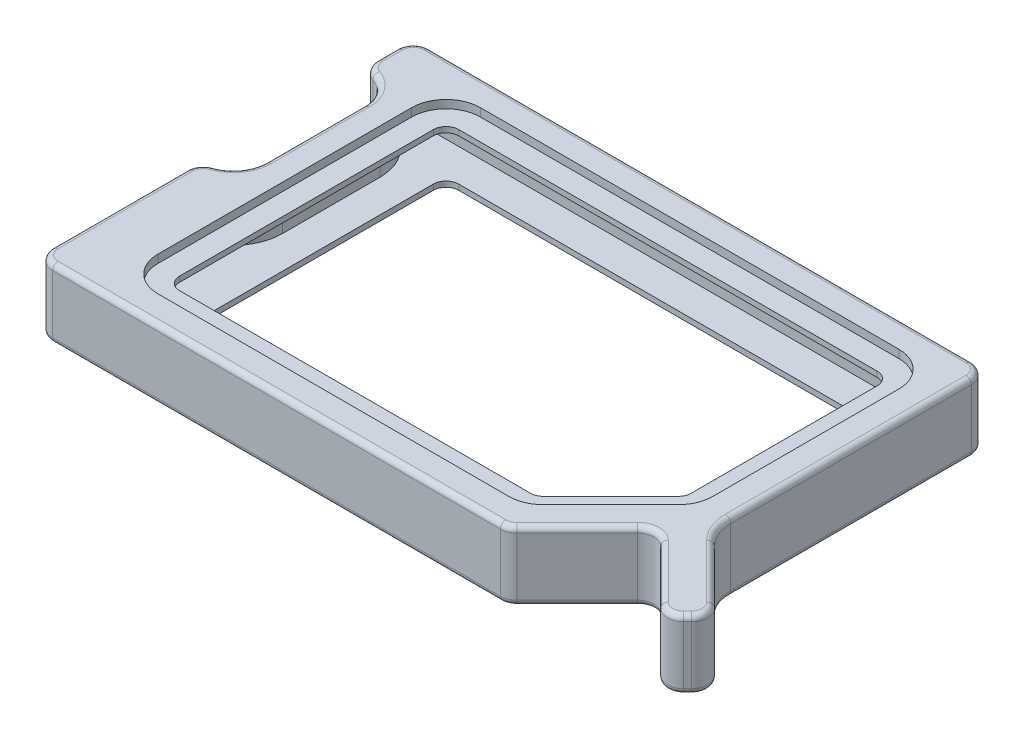
from build123d import *

# Parameters (mm, degrees)
SKETCH1_W           = 120
SKETCH1_H           = 69.434382776
BOSS_EXTRUDE1_DEPTH = 6.35
CUT_EXTRUDE1_DEPTH  = 7.35
FILLET1_R           = 3
BOSS_EXTRUDE2_DEPTH = 6.35
CUT_EXTRUDE2_DEPTH  = 1.5
FILLET2_R           = 6.35
CUT_EXTRUDE3_REACH  = 6.85
CUT_EXTRUDE4_DEPTH  = 3.85
BOSS_EXTRUDE3_DEPTH = 3.85
FILLET4_R           = 1
SKETCH8_R           = 1.799581827
CUT_EXTRUDE5_DEPTH  = 21
FILLET5_R           = 1
CUT_EXTRUDE6_START  = -3.5
SKETCH9_W           = 12.800190858
SKETCH9_H           = 9.638233658
CUT_EXTRUDE6_DEPTH  = 1.6


with BuildPart() as part:
    # Sketch1 → Boss-Extrude1 (new body)
    with BuildSketch(Plane(origin=(0, 0, 0), x_dir=(1, 0, 0), z_dir=(0, 1, 0))):
        Rectangle(SKETCH1_W, SKETCH1_H)
    extrude(amount=BOSS_EXTRUDE1_DEPTH)

    # Sketch2 → Cut-Extrude1 (cut, through all)
    with BuildSketch(Plane(origin=(0, 6.35, 0), x_dir=(1, 0, 0), z_dir=(0, 1, 0))):
        with BuildLine():
            Line((-53.945604382, 19.556024572), (-53.945604382, 1.562036653))
            ThreePointArc((-53.945604382, 1.562036653), (-60, -4.492358965), (-66.054395618, 1.562036653))
            Line((-66.054395618, 1.562036653), (-66.054395618, 19.556024572))
            ThreePointArc((-66.054395618, 19.556024572), (-60, 25.61042019), (-53.945604382, 19.556024572))
        make_face()
        Polygon((26.765981284, -34.717191388), (40.908116908, -20.575055764), (55.050252532, -34.717191388), (60, -29.767443919), (45.857864376, -15.625308296), (45.857864376, 34.717191388), (85.563511745, 34.717191388), (85.563511745, -46.950332747), (26.765981284, -46.950332747), align=None)
    extrude(amount=-CUT_EXTRUDE1_DEPTH, mode=Mode.SUBTRACT)

    # Fillet1
    fillet1_edges = [part.edges().sort_by_distance(p)[0] for p in [
        (-60, 3.175, -25.61042019),
        (-60, 3.175, 4.492358965),
        (45.857864376, 3.175, -34.717191388),
        (26.765981284, 3.175, 34.717191388),
        (40.908116908, 3.175, 20.575055764),
        (55.050252532, 3.175, 34.717191388),
        (60, 3.175, 29.767443919),
        (-60, 3.175, -34.717191388),
        (-60, 3.175, 34.717191388),
    ]]
    fillet(fillet1_edges, radius=FILLET1_R)

    # Sketch3 → Boss-Extrude2 (add)
    with BuildSketch(Plane(origin=(0, 6.35, 0), x_dir=(1, 0, 0), z_dir=(0, 1, 0))):
        with BuildLine():
            Line((47.97918472, -17.746628639), (49.552046941, -19.31949086))
            Line((49.552046941, -19.31949086), (42.644119977, -16.529838006))
            Line((42.644119977, -16.529838006), (45.857864376, -12.623439694))
            ThreePointArc((45.857864376, -12.623439694), (46.408820018, -15.39608369), (47.97918472, -17.746628639))
        make_face()
    extrude(amount=-BOSS_EXTRUDE2_DEPTH)

    # Sketch4 → Cut-Extrude2 (cut)
    with BuildSketch(Plane(origin=(0, 6.35, 0), x_dir=(1, 0, 0), z_dir=(0, 1, 0))):
        Polygon((-48.945604382, 29.717191388), (-48.945604382, -29.717191388), (24.694913472, -29.717191388), (40.857864376, -13.554240484), (40.857864376, 29.717191388), align=None)
    extrude(amount=-CUT_EXTRUDE2_DEPTH, mode=Mode.SUBTRACT)

    # Fillet2
    fillet2_edges = [part.edges().sort_by_distance(p)[0] for p in [
        (-48.945604382, 5.6, -29.717191388),
        (40.857864376, 5.6, -29.717191388),
        (40.857864376, 5.6, 13.554240484),
        (24.694913472, 5.6, 29.717191388),
        (-48.945604382, 5.6, 29.717191388),
    ]]
    fillet(fillet2_edges, radius=FILLET2_R)

    # Sketch5 → Cut-Extrude3 (cut, up to next)
    with BuildSketch(Plane(origin=(0, 4.85, 0), x_dir=(1, 0, 0), z_dir=(0, 1, 0)), mode=Mode.PRIVATE) as cut_extrude3_sk1:
        with BuildLine():
            Line((-44.945604382, 23.367191388), (-44.945604382, -23.367191388))
            ThreePointArc((-44.945604382, -23.367191388), (-44.257305317, -25.028892323), (-42.595604382, -25.717191388))
            Line((-42.595604382, -25.717191388), (22.064657351, -25.717191388))
            ThreePointArc((22.064657351, -25.717191388), (22.963963417, -25.538308289), (23.726358287, -25.028892323))
            Line((23.726358287, -25.028892323), (36.169565312, -12.585685298))
            ThreePointArc((36.169565312, -12.585685298), (36.678981278, -11.823290429), (36.857864376, -10.923984363))
            Line((36.857864376, -10.923984363), (36.857864376, 23.367191388))
            ThreePointArc((36.857864376, 23.367191388), (36.169565312, 25.028892323), (34.507864376, 25.717191388))
            Line((34.507864376, 25.717191388), (-42.595604382, 25.717191388))
            ThreePointArc((-42.595604382, 25.717191388), (-44.257305317, 25.028892323), (-44.945604382, 23.367191388))
        make_face()
    cut_extrude3_tool1 = extrude(cut_extrude3_sk1.sketch, amount=-CUT_EXTRUDE3_REACH, mode=Mode.PRIVATE) & part.part
    add(cut_extrude3_tool1.solids().sort_by_distance((-4.877844, 4.85, -0.484519))[0], mode=Mode.SUBTRACT)

    # Sketch6 → Cut-Extrude4 (cut)
    with BuildSketch(Plane.XZ):
        with BuildLine():
            Line((42.857864376, -31.717191388), (42.857864376, 12.625307714))
            ThreePointArc((42.857864376, 12.625307714), (43.637538907, 16.544996877), (45.857864461, 19.867948897))
            Line((45.857864461, 19.867948897), (55.757359313, 29.767443919))
            Line((55.757359313, 29.767443919), (55.050252532, 30.4745507))
            Line((55.050252532, 30.4745507), (45.150757595, 20.575055764))
            ThreePointArc((45.150757595, 20.575055764), (40.908116908, 18.817696451), (36.665476221, 20.575055764))
            Line((36.665476221, 20.575055764), (25.523340597, 31.717191388))
            Line((25.523340597, 31.717191388), (-57, 31.717191388))
            Line((-57, 31.717191388), (-57, 6.98091834))
            ThreePointArc((-57, 6.98091834), (-52.612670751, 3.673366538), (-50.945604382, -1.562036653))
            Line((-50.945604382, -1.562036653), (-50.945604382, -19.556024572))
            ThreePointArc((-50.945604382, -19.556024572), (-52.612670751, -24.791427763), (-57, -28.098979565))
            Line((-57, -28.098979565), (-57, -31.717191388))
            Line((-57, -31.717191388), (42.857864376, -31.717191388))
        make_face()
    extrude(amount=-CUT_EXTRUDE4_DEPTH, mode=Mode.SUBTRACT)

    # Sketch7 → Boss-Extrude3 (add)
    with BuildSketch(Plane.XZ):
        with BuildLine():
            ThreePointArc((42.857864376, 12.625307714), (42.534912477, 14.248896552), (41.615223278, 15.625308707))
            Line((41.615223278, 15.625308707), (36.665476221, 20.575055764))
            ThreePointArc((36.665476221, 20.575055764), (40.908116908, 18.817696451), (45.150757595, 20.575055764))
            Line((45.150757595, 20.575055764), (55.050252532, 30.4745507))
            Line((55.050252532, 30.4745507), (55.757359313, 29.767443919))
            Line((55.757359313, 29.767443919), (45.857864461, 19.867948897))
            ThreePointArc((45.857864461, 19.867948897), (43.637538907, 16.544996877), (42.857864376, 12.625307714))
        make_face()
    extrude(amount=-BOSS_EXTRUDE3_DEPTH)

    # Fillet4
    fillet4_edges = [part.edges().sort_by_distance(p)[0] for p in [
        (52.928932188, 6.35, 22.696376107),
        (46.408820018, 6.35, 15.39608369),
        (-55.060320344, 6.35, -23.056777519),
        (-53.945604382, 6.35, -10.559030613),
        (-60, 6.35, 19.349054864),
        (-55.060320344, 6.35, 1.938716294),
        (-15.738329701, 6.35, 34.717191388),
        (33.215728753, 6.35, 28.267443919),
        (47.97918472, 6.35, 27.646123576),
        (57.525126266, 6.35, 32.242317653),
        (45.857864376, 6.35, -9.546875847),
        (-7.071067812, 6.35, -34.717191388),
        (-60, 6.35, -29.908085476),
        (-59.121320344, 6.35, -33.838511731),
        (-59.121320344, 6.35, 33.838511731),
        (26.671390894, 6.35, 34.488829985),
        (55.050252532, 6.35, 33.4745507),
        (58.757359313, 6.35, 29.767443919),
        (44.97918472, 6.35, -33.838511731),
        (-59.447649593, 6.35, -26.36432932),
        (-59.447649593, 6.35, 5.246268095),
        (40.908116908, 6.35, 21.817696451),
    ]]
    fillet(fillet4_edges, radius=FILLET4_R)

    # Mirror1: part across plane


with BuildPart() as part_1:
    add(part.part)
    add(part.part.mirror(Plane(origin=(0, 0, 0), x_dir=(0, 0, 1), z_dir=(0, -1, 0))))

    # Sketch8 → Cut-Extrude5 (cut)
    with BuildSketch(Plane.ZY.offset(60)):
        with Locations((-15.556024572, 0)):
            Circle(SKETCH8_R)
        with Locations((-5.562036653, 0)):
            Circle(SKETCH8_R)
        with Locations((26.913689905, 0)):
            Circle(SKETCH8_R)
        Polygon((9.842674222, 1.799581827), (18.178626353, 1.799581827), (16.100648249, -1.799581827), (11.920652326, -1.799581827), align=None)
    extrude(amount=-CUT_EXTRUDE5_DEPTH, mode=Mode.SUBTRACT)

    # Fillet5
    fillet5_edges = [part_1.edges().sort_by_distance(p)[0] for p in [
        (-58.5, -1.799581827, 11.920652326),
        (-58.5, 1.799581827, 9.842674222),
        (-58.5, 1.799581827, 18.178626353),
        (-58.5, -1.799581827, 16.100648249),
    ]]
    fillet(fillet5_edges, radius=FILLET5_R)

    # Sketch9 → Cut-Extrude6 (cut)
    with BuildSketch(Plane(origin=(12.641404306, 0, -12.641404306), x_dir=(0.707106781, 0, 0.707106781), z_dir=(-0.707106781, 0, 0.707106781)).offset(CUT_EXTRUDE6_START)):
        with Locations((53.534782746, 0)):
            Rectangle(SKETCH9_W, SKETCH9_H)
    extrude(amount=CUT_EXTRUDE6_DEPTH, mode=Mode.SUBTRACT)


solid = part_1.part
